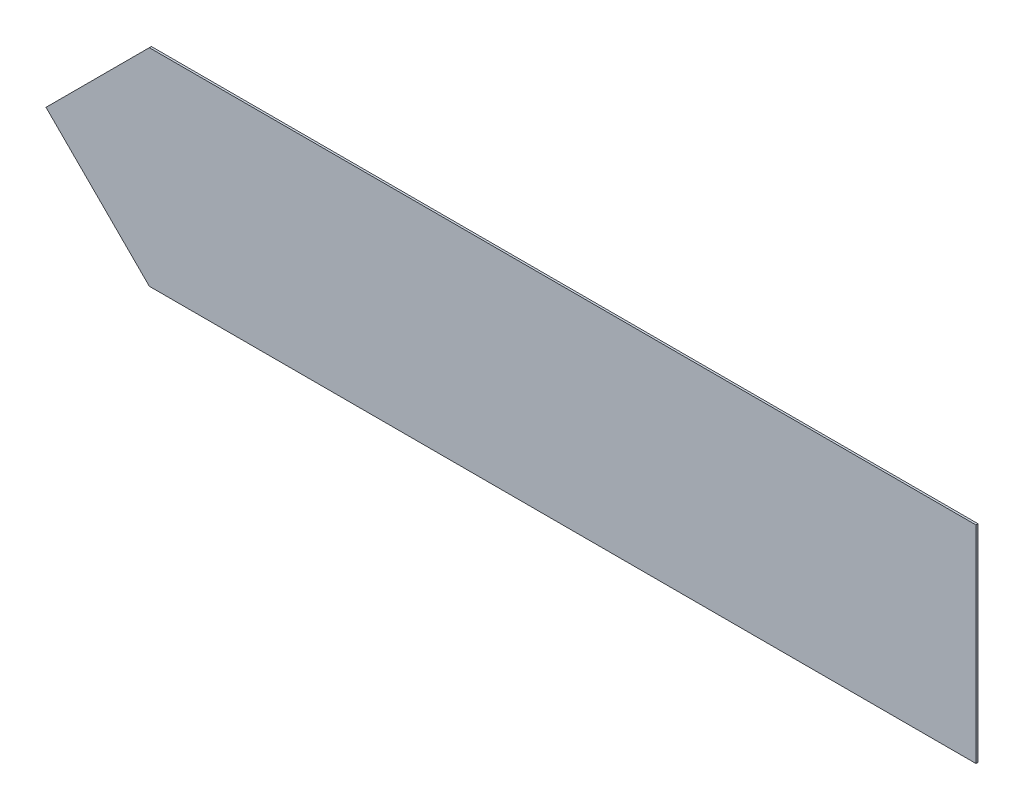
from build123d import *

# Parameters (mm, degrees)
BOSS_EXTRUDE1_DEPTH = 0.254


with BuildPart() as part:
    # Sketch1 → Boss-Extrude1 (new body)
    with BuildSketch(Plane.XY):
        Polygon((0, 0), (12.7, 12.7), (114.3, 12.7), (114.3, -12.7), (12.7, -12.7), align=None)
    extrude(amount=BOSS_EXTRUDE1_DEPTH)


solid = part.part
